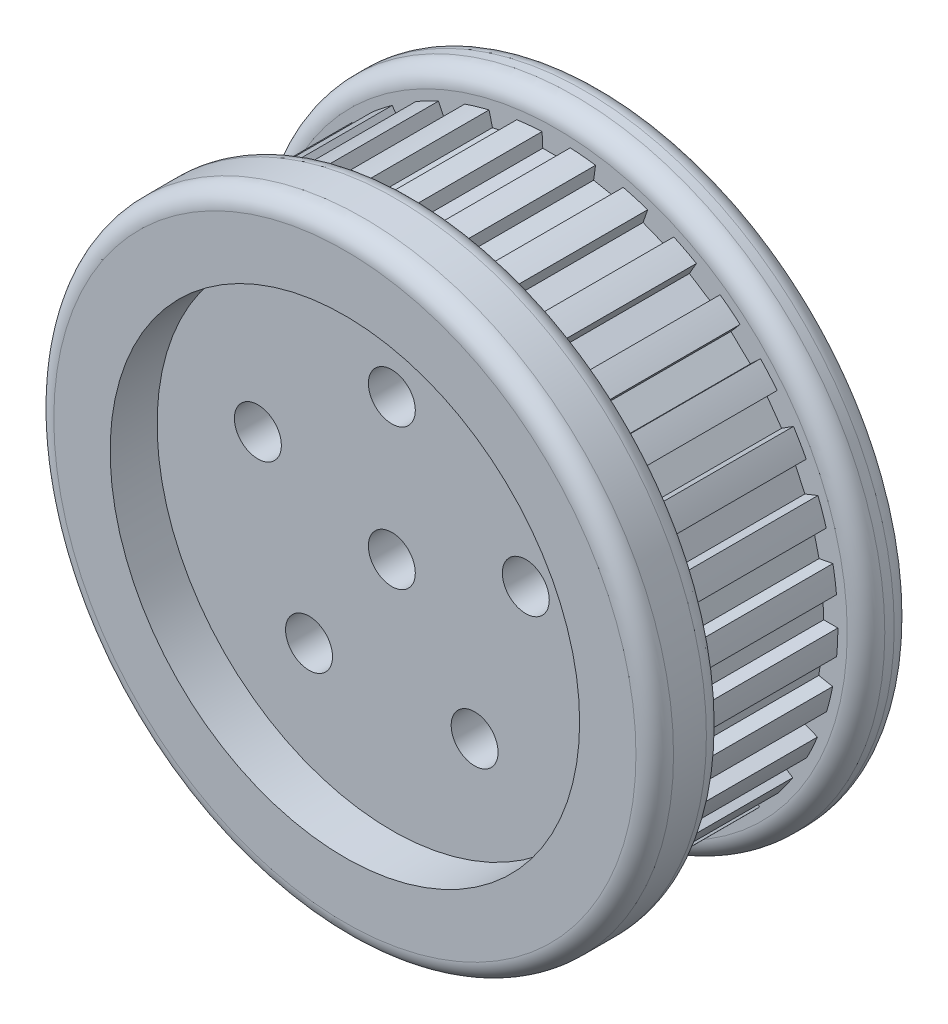
from build123d import *

# Parameters (mm, degrees)
FILLET1_R          = 2
SKETCH2_R          = 2.5
CUT_EXTRUDE1_DEPTH = 16
CUT_EXTRUDE2_DEPTH = 15
CIRPATTERN1_COUNT  = 33


with BuildPart() as part:
    # Sketch1 → Revolve1 (revolve)
    with BuildSketch(Plane(origin=(0, 0, 0), x_dir=(1, 0, 0), z_dir=(0, 1, 0))):
        Polygon((0, 0), (0, 10), (25, 10), (25, 22.5), (33, 22.5), (33, 17.5), (30, 17.5), (30, 2.5), (33, 2.5), (33, -5), (25, -5), (25, 0), align=None)
    revolve(axis=Axis((0, 0, 0), (0, 0, -1)))

    # Fillet1
    fillet1_edges = [part.edges().sort_by_distance(p)[0] for p in [
        (-33, 0, 5),
        (-33, 0, -2.5),
        (-33, 0, -17.5),
        (-33, 0, -22.5),
    ]]
    fillet(fillet1_edges, radius=FILLET1_R)

    # Sketch2 → Cut-Extrude1 (cut, through all)
    with BuildSketch(Plane(origin=(0, 0, -10), x_dir=(-1, 0, 0), z_dir=(0, 0, -1))):
        Circle(SKETCH2_R)
        with Locations((0, 15)):
            Circle(SKETCH2_R)
        with Locations((14.265847744, 4.635254916)):
            Circle(SKETCH2_R)
        with Locations((8.816778784, -12.135254916)):
            Circle(SKETCH2_R)
        with Locations((-8.816778784, -12.135254916)):
            Circle(SKETCH2_R)
        with Locations((-14.265847744, 4.635254916)):
            Circle(SKETCH2_R)
    extrude(amount=-CUT_EXTRUDE1_DEPTH, mode=Mode.SUBTRACT)

    # Sketch3 → Cut-Extrude2 (cut)
    with BuildSketch(Plane(origin=(0, 0, -2.5), x_dir=(-1, 0, 0), z_dir=(0, 0, -1))):
        with BuildLine():
            Line((-1.424906074, 28.462476533), (1.424906074, 28.462476533))
            Line((1.424906074, 28.462476533), (1.5, 29.962476533))
            ThreePointArc((1.5, 29.962476533), (0, 30), (-1.5, 29.962476533))
            Line((-1.5, 29.962476533), (-1.424906074, 28.462476533))
        make_face()
    cut_extrude2 = extrude(amount=CUT_EXTRUDE2_DEPTH, mode=Mode.SUBTRACT)

    # CirPattern1: Cut-Extrude2 ×33 about axis
    cirpattern1_axis = Axis((0, 0, 0), (0, 0, 1))
    for i in range(1, CIRPATTERN1_COUNT):
        add(cut_extrude2.rotate(cirpattern1_axis, i * 360 / CIRPATTERN1_COUNT), mode=Mode.SUBTRACT)


solid = part.part
